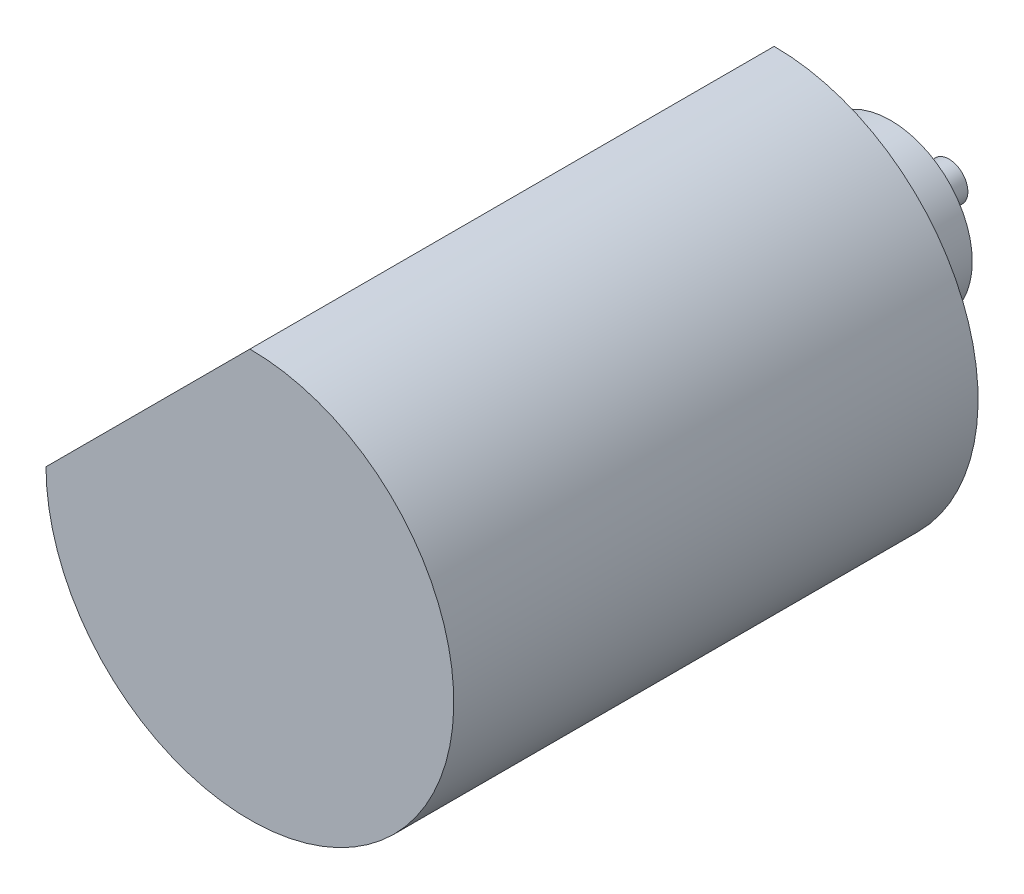
from build123d import *

# Parameters (mm, degrees)
EXTRUDE_1_DEPTH = 45
SKETCH_2_R      = 1.625
EXTRUDE_2_DEPTH = 15
SKETCH_3_R      = 7
EXTRUDE_3_DEPTH = 10


with BuildPart() as part:
    # 草图1 → 凸台-拉伸1 (new body)
    with BuildSketch(Plane.XY):
        with BuildLine():
            Line((0, 17.5), (-17.5, 0))
            ThreePointArc((-17.5, 0), (12.374368671, -12.374368671), (0, 17.5))
        make_face()
    extrude(amount=EXTRUDE_1_DEPTH)

    # 草图2 → 凸台-拉伸2 (add)
    with BuildSketch(Plane(origin=(0, 0, 0), x_dir=(-1, 0, 0), z_dir=(0, 0, -1))):
        Circle(SKETCH_2_R)
    extrude(amount=EXTRUDE_2_DEPTH)

    # 草图3 → 凸台-拉伸3 (add)
    with BuildSketch(Plane(origin=(0, 0, 0), x_dir=(-1, 0, 0), z_dir=(0, 0, -1))):
        Circle(SKETCH_3_R)
    extrude(amount=EXTRUDE_3_DEPTH)


solid = part.part
